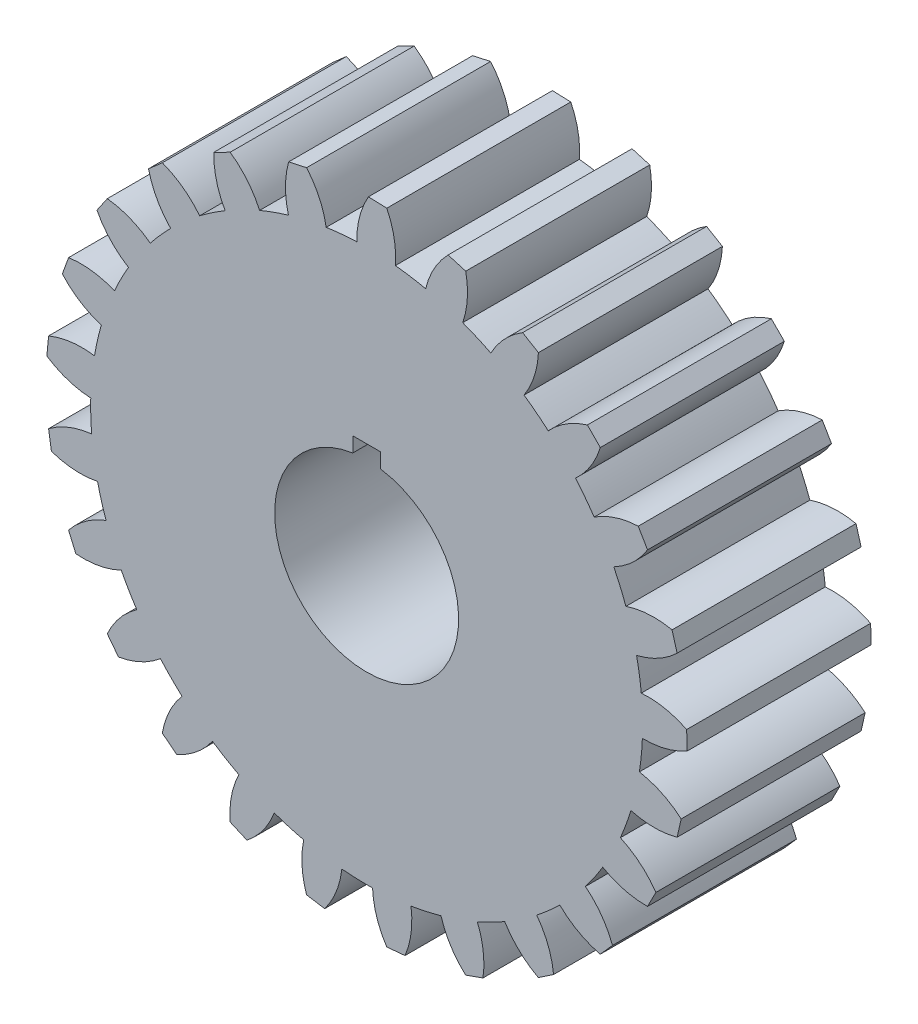
from build123d import *

# Parameters (mm, degrees)
SKETCH1_R           = 152.4
BOSS_EXTRUDE1_DEPTH = 101.6
CUT_EXTRUDE1_DEPTH  = 102.6
BOSS_EXTRUDE3_DEPTH = 101.6


with BuildPart() as part:
    # Sketch1 → Boss-Extrude1 (new body)
    with BuildSketch(Plane.XY):
        Circle(SKETCH1_R)
    extrude(amount=BOSS_EXTRUDE1_DEPTH)

    # Sketch2 → Cut-Extrude1 (cut, through all)
    with BuildSketch(Plane.XY.offset(101.6)):
        with BuildLine():
            Line((-7.62, 50.225248631), (-7.62, 58.42))
            Line((-7.62, 58.42), (7.62, 58.42))
            Line((7.62, 58.42), (7.62, 50.225248631))
            ThreePointArc((7.62, 50.225248631), (0, -50.8), (-7.62, 50.225248631))
        make_face()
    extrude(amount=-CUT_EXTRUDE1_DEPTH, mode=Mode.SUBTRACT)

    # Sketch3 → Boss-Extrude3 (add)
    with BuildSketch(Plane.XY.offset(101.6)):
        with BuildLine():
            Line((0.984560076, 177.011085759), (11.138596509, 176.66302813))
            ThreePointArc((11.138596509, 176.66302813), (15.196562883, 164.436371227), (15.869603853, 151.571487007))
            ThreePointArc((15.869603853, 151.571487007), (5.22086444, 152.310546498), (-5.453487698, 152.302394833))
            ThreePointArc((-5.453487698, 152.302394833), (-3.901102684, 165.090996434), (0.984560076, 177.011085759))
        make_face()
        with BuildLine():
            Line((44.974495255, 171.205106866), (54.722965549, 168.342777932))
            ThreePointArc((54.722965549, 168.342777932), (55.612797522, 155.491068739), (53.065327067, 142.862980031))
            ThreePointArc((53.065327067, 142.862980031), (42.934934006, 146.227054412), (32.593909032, 148.873762275))
            ThreePointArc((32.593909032, 148.873762275), (37.277918906, 160.874523986), (44.974495255, 171.205106866))
        make_face()
        with BuildLine():
            Line((86.138517492, 154.641681459), (94.868889406, 149.444931875))
            ThreePointArc((94.868889406, 149.444931875), (92.534675563, 136.775690545), (86.926760621, 125.177866606))
            ThreePointArc((86.926760621, 125.177866606), (77.951243764, 130.955578711), (68.593310586, 136.090843714))
            ThreePointArc((68.593310586, 136.090843714), (76.114631752, 146.549713541), (86.138517492, 154.641681459))
        make_face()
        with BuildLine():
            Line((121.890139881, 128.361550474), (129.053852039, 121.156911128))
            ThreePointArc((129.053852039, 121.156911128), (123.642259619, 109.46619269), (115.326266111, 99.62736745))
            ThreePointArc((115.326266111, 99.62736745), (108.069590193, 107.455682379), (100.282742167, 114.756836935))
            ThreePointArc((100.282742167, 114.756836935), (110.168782355, 123.016645622), (121.890139881, 128.361550474))
        make_face()
        with BuildLine():
            Line((149.9829565, 94.015991192), (155.129886522, 85.256156071))
            ThreePointArc((155.129886522, 85.256156071), (146.980945779, 75.278531359), (136.47939816, 67.816914393))
            ThreePointArc((136.47939816, 67.816914393), (131.397526817, 77.203950329), (125.671040244, 86.212236046))
            ThreePointArc((125.671040244, 86.212236046), (137.30062319, 91.753989435), (149.9829565, 94.015991192))
        make_face()
        with BuildLine():
            Line((168.651792363, 53.763061417), (171.458539706, 43.998443178))
            ThreePointArc((171.458539706, 43.998443178), (161.084278558, 36.360843047), (149.057027687, 31.745275192))
            ThreePointArc((149.057027687, 31.745275192), (146.469273585, 42.101210144), (143.162964676, 52.250603299))
            ThreePointArc((143.162964676, 52.250603299), (155.805360914, 54.726092645), (168.651792363, 53.763061417))
        make_face()
        with BuildLine():
            Line((176.723615855, 10.132000766), (177.01382226, -0.023853715))
            ThreePointArc((177.01382226, -0.023853715), (165.066093688, -4.841530759), (152.268855971, -6.3210364))
            ThreePointArc((152.268855971, -6.3210364), (152.337817217, 4.353096088), (151.659433521, 15.005872983))
            ThreePointArc((151.659433521, 15.005872983), (164.520274799, 14.259554184), (176.723615855, 10.132000766))
        make_face()
        with BuildLine():
            Line((173.691244618, -34.135690756), (171.446675351, -44.044651791))
            ThreePointArc((171.446675351, -44.044651791), (158.676199082, -45.739693381), (145.913072029, -43.990174028))
            ThreePointArc((145.913072029, -43.990174028), (148.634415534, -33.668539005), (150.626582394, -23.181731521))
            ThreePointArc((150.626582394, -23.181731521), (162.897774756, -27.102964508), (173.691244618, -34.135690756))
        make_face()
        with BuildLine():
            Line((159.74521369, -76.258511285), (155.106903292, -85.297962411))
            ThreePointArc((155.106903292, -85.297962411), (142.316095317, -83.76386285), (130.389033141, -78.895247238))
            ThreePointArc((130.389033141, -78.895247238), (135.591766884, -69.574655969), (140.129309129, -59.912742576))
            ThreePointArc((140.129309129, -59.912742576), (151.039808429, -66.762504263), (159.74521369, -76.258511285))
        make_face()
        with BuildLine():
            Line((135.761803484, -113.589729091), (129.021194056, -121.191688348))
            ThreePointArc((129.021194056, -121.191688348), (117.013747881, -116.524840753), (106.672171762, -108.843041907))
            ThreePointArc((106.672171762, -108.843041907), (114.02938885, -101.109141419), (120.827196012, -92.879215672))
            ThreePointArc((120.827196012, -92.879215672), (129.691455452, -102.227110339), (135.761803484, -113.589729091))
        make_face()
        with BuildLine():
            Line((103.247979869, -143.783686465), (94.828608691, -149.470494794))
            ThreePointArc((94.828608691, -149.470494794), (84.358996319, -141.964134364), (76.25270552, -131.951827956))
            ThreePointArc((76.25270552, -131.951827956), (85.302124943, -126.290567662), (93.933065798, -120.009746062))
            ThreePointArc((93.933065798, -120.009746062), (100.194111358, -131.268411108), (103.247979869, -143.783686465))
        make_face()
        with BuildLine():
            Line((64.246705958, -164.943186018), (54.677593087, -168.357520338))
            ThreePointArc((54.677593087, -168.357520338), (46.403658768, -158.483299305), (41.042001351, -146.76959537))
            ThreePointArc((41.042001351, -146.76959537), (51.215014806, -143.536693073), (61.136775598, -139.599622741))
            ThreePointArc((61.136775598, -139.599622741), (64.401202759, -152.061634836), (64.246705958, -164.943186018))
        make_face()
        with BuildLine():
            Line((21.20857523, -175.738698575), (11.090983218, -176.666023704))
            ThreePointArc((11.090983218, -176.666023704), (5.532608676, -165.04437569), (3.252477296, -152.365289326))
            ThreePointArc((3.252477296, -152.365289326), (13.909876934, -151.763880168), (24.499036942, -150.417941712))
            ThreePointArc((24.499036942, -150.417941712), (24.561729739, -163.300266803), (21.20857523, -175.738698575))
        make_face()
        with BuildLine():
            Line((-23.16216828, -175.49190238), (-33.192513915, -173.873951069))
            ThreePointArc((-33.192513915, -173.873951069), (-35.686075567, -161.23510696), (-34.74141187, -148.387311794))
            ThreePointArc((-34.74141187, -148.387311794), (-24.269269663, -150.455184524), (-13.678066306, -151.784948207))
            ThreePointArc((-13.678066306, -151.784948207), (-16.821047091, -164.27814243), (-23.16216828, -175.49190238))
        make_face()
        with BuildLine():
            Line((-66.077547573, -164.218304543), (-75.390403326, -160.156738624))
            ThreePointArc((-75.390403326, -160.156738624), (-74.662472438, -147.294843478), (-70.552370357, -135.085613731))
            ThreePointArc((-70.552370357, -135.085613731), (-60.923488791, -139.6928363), (-50.995726343, -143.61474818))
            ThreePointArc((-50.995726343, -143.61474818), (-57.14689567, -154.933818196), (-66.077547573, -164.218304543))
        make_face()
        with BuildLine():
            Line((-104.841031535, -142.62626668), (-112.851236429, -136.376289276))
            ThreePointArc((-112.851236429, -136.376289276), (-108.947551576, -124.099503267), (-101.930263942, -113.295989747))
            ThreePointArc((-101.930263942, -113.295989747), (-93.749661058, -120.153073417), (-85.109137346, -126.420705346))
            ThreePointArc((-85.109137346, -126.420705346), (-93.881994622, -135.854432358), (-104.841031535, -142.62626668))
        make_face()
        with BuildLine():
            Line((-137.016967907, -112.072495938), (-143.22121131, -104.026816116))
            ThreePointArc((-143.22121131, -104.026816116), (-136.387055368, -93.106534861), (-126.90350417, -84.387562054))
            ThreePointArc((-126.90350417, -84.387562054), (-120.685197332, -93.06365104), (-113.874828239, -101.283184653))
            ThreePointArc((-113.874828239, -101.283184653), (-124.718142578, -108.238812898), (-137.016967907, -112.072495938))
        make_face()
        with BuildLine():
            Line((-160.583624273, -74.476798103), (-164.592070753, -65.140955515))
            ThreePointArc((-164.592070753, -65.140955515), (-155.256858874, -56.263340447), (-143.902930513, -50.176753481))
            ThreePointArc((-143.902930513, -50.176753481), (-140.03763881, -60.126697203), (-135.485344872, -69.781668975))
            ThreePointArc((-135.485344872, -69.781668975), (-147.717790955, -73.822150748), (-160.583624273, -74.476798103))
        make_face()
        with BuildLine():
            Line((-174.06022094, -32.201449136), (-175.621005064, -22.162049108))
            ThreePointArc((-175.621005064, -22.162049108), (-164.371302942, -15.884913431), (-151.860406493, -12.81315495))
            ThreePointArc((-151.860406493, -12.81315495), (-150.591000419, -23.411761851), (-148.582819006, -33.895514396))
            ThreePointArc((-148.582819006, -33.895514396), (-161.435787258, -34.766971368), (-174.06022094, -32.201449136))
        make_face()
        with BuildLine():
            Line((-176.599973777, 12.097235308), (-175.615025737, 22.209380351))
            ThreePointArc((-175.615025737, 22.209380351), (-163.157693531, 25.491621116), (-150.27593463, 25.35554123))
            ThreePointArc((-150.27593463, 25.35554123), (-151.682175636, 14.774220601), (-152.344288173, 4.120420012))
            ThreePointArc((-152.344288173, 4.120420012), (-165.010179328, 6.472744687), (-176.599973777, 12.097235308))
        make_face()
        with BuildLine():
            Line((-168.043300773, 55.635805968), (-164.574508477, 65.185312762))
            ThreePointArc((-164.574508477, 65.185312762), (-151.692286184, 65.266423358), (-139.249073118, 61.931055503))
            ThreePointArc((-139.249073118, 61.931055503), (-143.24260191, 52.031884437), (-146.533405431, 41.877453276))
            ThreePointArc((-146.533405431, 41.877453276), (-158.216374966, 47.305754388), (-168.043300773, 55.635805968))
        make_face()
        with BuildLine():
            Line((-148.92784916, 95.678574324), (-143.193169586, 104.065412237))
            ThreePointArc((-143.193169586, 104.065412237), (-130.695494611, 100.940296186), (-119.47268022, 94.615213793))
            ThreePointArc((-119.47268022, 94.615213793), (-125.802568697, 86.020193614), (-131.515289913, 77.003172136))
            ThreePointArc((-131.515289913, 77.003172136), (-141.481253886, 85.166369563), (-148.92784916, 95.678574324))
        make_face()
        with BuildLine():
            Line((-120.454713067, 129.709505975), (-112.814477223, 136.406699136))
            ThreePointArc((-112.814477223, 136.406699136), (-101.486624446, 130.271718973), (-92.189379433, 121.35435023))
            ThreePointArc((-92.189379433, 121.35435023), (-100.457897423, 114.603537665), (-108.233585051, 107.290498494))
            ThreePointArc((-108.233585051, 107.290498494), (-115.856345292, 117.675668518), (-120.454713067, 129.709505975))
        make_face()
        with BuildLine():
            Line((-84.41296435, 155.590312327), (-75.347236353, 160.17705146))
            ThreePointArc((-75.347236353, 160.17705146), (-65.900976426, 151.417690551), (-59.113480889, 140.468346531))
            ThreePointArc((-59.113480889, 140.468346531), (-68.801086995, 135.985919963), (-78.151165985, 130.836368244))
            ThreePointArc((-78.151165985, 130.836368244), (-82.951756434, 142.790972439), (-84.41296435, 155.590312327))
        make_face()
        with BuildLine():
            Line((-43.067238634, 171.694807134), (-33.145651515, 173.88289055))
            ThreePointArc((-33.145651515, 173.88289055), (-26.174527691, 163.049531756), (-22.323264935, 150.756200014))
            ThreePointArc((-22.323264935, 150.756200014), (-32.821251239, 148.823806789), (-43.15822174, 146.161307795))
            ThreePointArc((-43.15822174, 146.161307795), (-44.835003644, 158.934194413), (-43.067238634, 171.694807134))
        make_face()
    extrude(amount=-BOSS_EXTRUDE3_DEPTH)


solid = part.part
